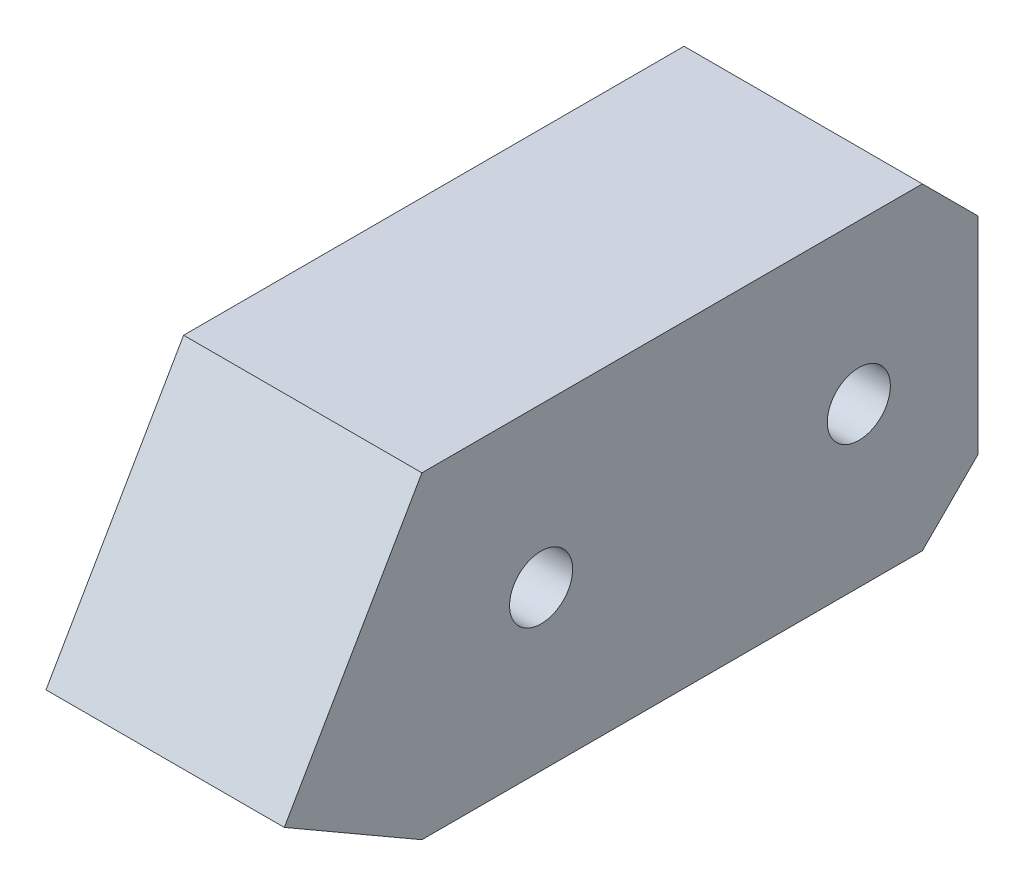
from build123d import *

# Parameters (mm, degrees)
ESBO_O1_R                = 3.97
RESSALTO_EXTRUS_O1_DEPTH = 15
ESBO_O2_R                = 3.97
CORTE_EXTRUS_O2_DEPTH    = 20
CHANFRO1_SIZE            = 7
ESBO_O4_R                = 3.97
CORTE_EXTRUS_O4_DEPTH    = 20


with BuildPart() as part:
    # Esboço1 → Ressalto-extrusão1 (new body, symmetric)
    with BuildSketch(Plane(origin=(0, 0, 0), x_dir=(0, 0, -1), z_dir=(1, 0, 0))):
        Polygon((35, 20), (-35, 20), (-52.320508076, -10), (-35, -20), (35, -20), align=None)
        with Locations((-20, 0)):
            Circle(ESBO_O1_R, mode=Mode.SUBTRACT)
        with Locations((20, 0)):
            Circle(ESBO_O1_R, mode=Mode.SUBTRACT)
    extrude(amount=RESSALTO_EXTRUS_O1_DEPTH, both=True)

    # Esboço2 → Corte-extrusão2 (cut)
    with BuildSketch(Plane.XZ.offset(20)):
        with Locations((0, 20)):
            Circle(ESBO_O2_R)
        with Locations((0, -20)):
            Circle(ESBO_O2_R)
    extrude(amount=-CORTE_EXTRUS_O2_DEPTH, mode=Mode.SUBTRACT)

    # Chanfro1
    chanfro1_edges = [part.edges().sort_by_distance(p)[0] for p in [
        (0, 20, -35),
        (0, -20, -35),
    ]]
    chamfer(chanfro1_edges, length=CHANFRO1_SIZE)

    # Esboço4 → Corte-extrusão4 (cut)
    with BuildSketch(Plane(origin=(0, -30.155444566, 17.410254038), x_dir=(1, 0, 0), z_dir=(0, -0.866025404, 0.5))):
        with Locations((0, 30.310889132)):
            Circle(ESBO_O4_R)
    extrude(amount=-CORTE_EXTRUS_O4_DEPTH, mode=Mode.SUBTRACT)


solid = part.part
